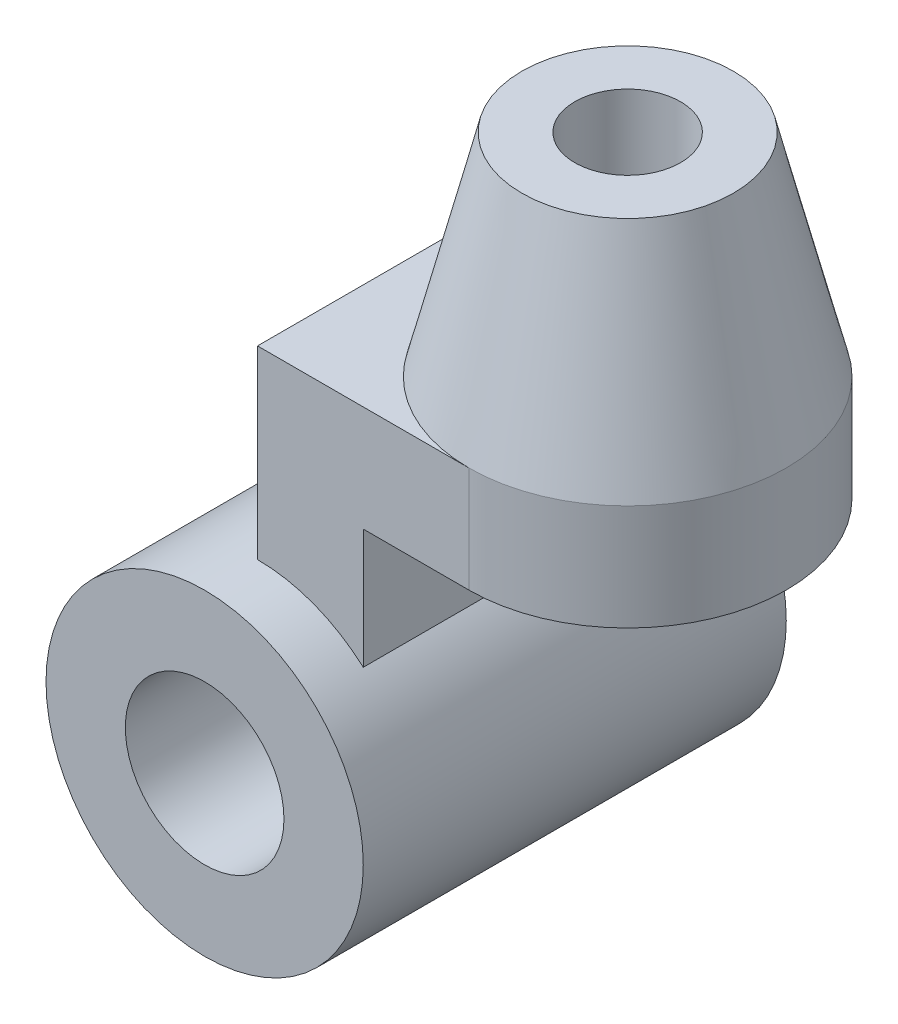
from build123d import *

# Parameters (mm, degrees)
SKETCH1_R           = 300
SKETCH1_R_2         = 150
BOSS_EXTRUDE1_DEPTH = 400
BOSS_EXTRUDE2_DEPTH = 300
SKETCH6_R           = 100
CUT_EXTRUDE1_DEPTH  = 951


with BuildPart() as part:
    # Sketch1 → Boss-Extrude1 (new body, symmetric)
    with BuildSketch(Plane.XY):
        Circle(SKETCH1_R)
        Circle(SKETCH1_R_2, mode=Mode.SUBTRACT)
    extrude(amount=BOSS_EXTRUDE1_DEPTH, both=True)

    # Sketch2 → Boss-Extrude2 (add, symmetric)
    with BuildSketch(Plane.XY):
        with BuildLine():
            Line((0, 300), (0, 650))
            Line((0, 650), (400, 650))
            Line((400, 650), (400, 450))
            Line((400, 450), (200, 450))
            Line((200, 450), (200, 223.60679775))
            ThreePointArc((200, 223.60679775), (107.046626932, 280.251707689), (0, 300))
        make_face()
    extrude(amount=BOSS_EXTRUDE2_DEPTH, both=True)

    # Sketch5 → Revolve1 (revolve)
    with BuildSketch(Plane.XY, mode=Mode.PRIVATE) as revolve1_sk:
        Polygon((500, 1050), (500, 450), (700, 450), (700, 650), (600, 1050), align=None)
    revolve(revolve1_sk.sketch.rotate(Axis((400, 1046.547462699, 0), (0, -1, 0)), 180), axis=Axis((400, 1046.547462699, 0), (0, -1, 0)))  # turned: the seam where the file's is

    # Sketch6 → Cut-Extrude1 (cut, through all)
    with BuildSketch(Plane(origin=(0, 650, 0), x_dir=(1, 0, 0), z_dir=(0, 1, 0))):
        with Locations(Location((400, 0, 0), (0, 0, 180))):  # turned: the seam where the file's is
            Circle(SKETCH6_R)
    extrude(amount=-CUT_EXTRUDE1_DEPTH, mode=Mode.SUBTRACT)


solid = part.part
